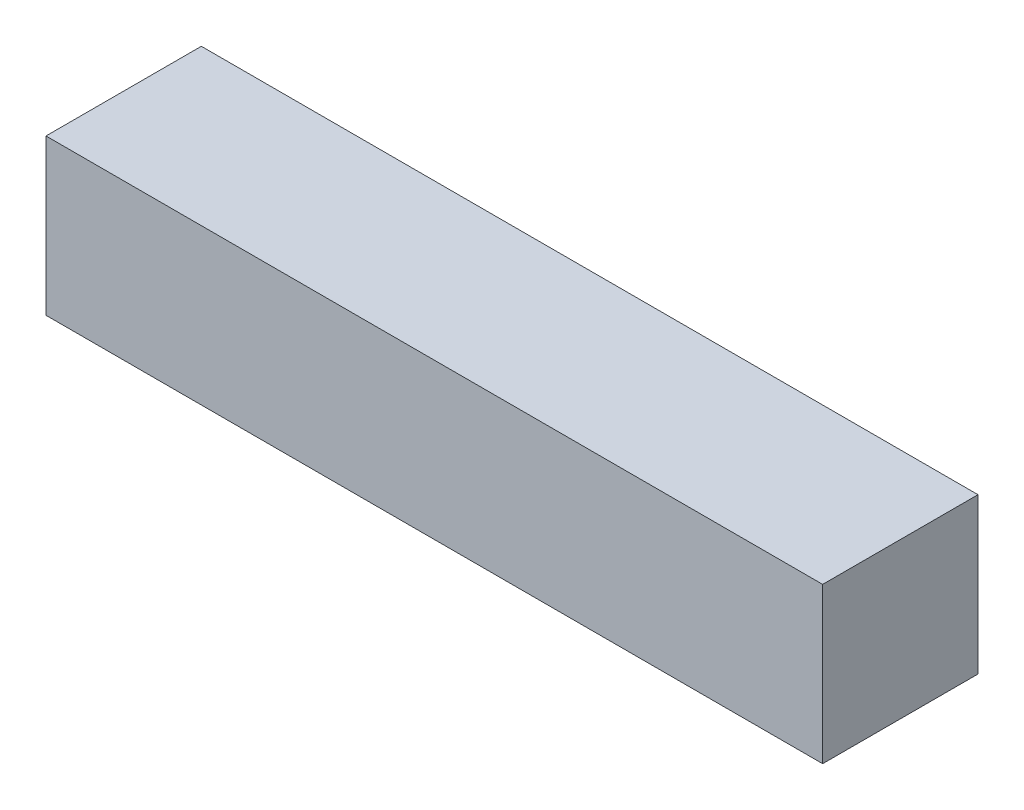
from build123d import *

# Parameters (mm, degrees)
SKETCH1_W           = 254
SKETCH1_H           = 50.8
BOSS_EXTRUDE1_DEPTH = 50.8


with BuildPart() as part:
    # Sketch1 → Boss-Extrude1 (new body)
    with BuildSketch(Plane(origin=(0, 0, 0), x_dir=(1, 0, 0), z_dir=(0, 1, 0))):
        Rectangle(SKETCH1_W, SKETCH1_H)
    extrude(amount=BOSS_EXTRUDE1_DEPTH)


solid = part.part
